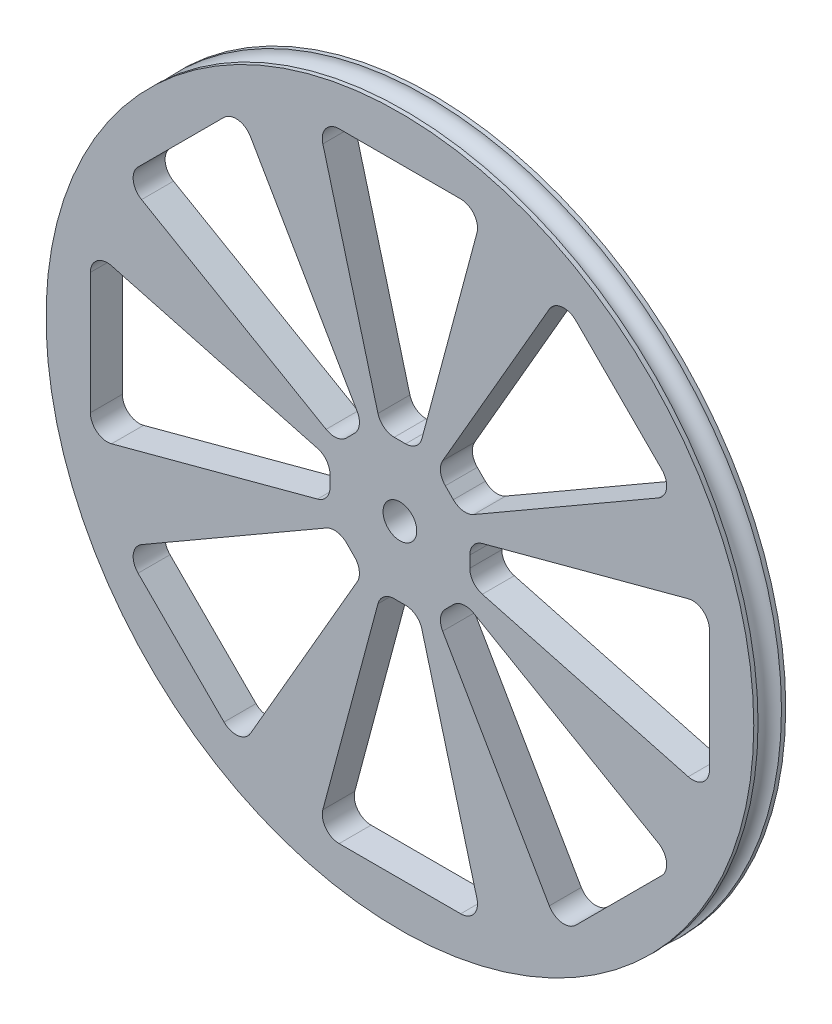
from build123d import *

# Parameters (mm, degrees)
CUT_EXTRUDE1_DEPTH = 7.62


with BuildPart() as part:
    # Sketch1 → Revolve1 (revolve)
    with BuildSketch(Plane(origin=(0, 0, 0), x_dir=(0, 0, -1), z_dir=(1, 0, 0))):
        with BuildLine():
            Line((-2.409610907, -44.48919659), (-2.409610907, 6.31080341))
            Line((-2.409610907, 6.31080341), (-1.7653, 6.31080341))
            ThreePointArc((-1.7653, 6.31080341), (0, 4.54550341), (1.7653, 6.31080341))
            Line((1.7653, 6.31080341), (2.409610907, 6.31080341))
            Line((2.409610907, 6.31080341), (2.409610907, -44.48919659))
            Line((2.409610907, -44.48919659), (-2.409610907, -44.48919659))
        make_face()
    revolve(axis=Axis((0, -47.02919659, 19.251181834), (0, 0, -1)))

    # Sketch2 → Cut-Extrude1 (cut)
    with BuildSketch(Plane(origin=(0, 0, -2.409610907), x_dir=(-1, 0, 0), z_dir=(0, 0, -1))):
        with BuildLine():
            Line((-9.161557863, -0.373493478), (9.161557863, -0.373493478))
            ThreePointArc((9.161557863, -0.373493478), (11.176404431, -1.366886448), (11.615239648, -3.570034182))
            Line((11.615239648, -3.570034182), (3.310434261, -34.607484824))
            ThreePointArc((3.310434261, -34.607484824), (2.403359506, -35.965790688), (0.856752476, -36.490944119))
            Line((0.856752476, -36.490944119), (-0.856752476, -36.490944119))
            ThreePointArc((-0.856752476, -36.490944119), (-2.403359506, -35.965790688), (-3.310434261, -34.607484824))
            Line((-3.310434261, -34.607484824), (-11.615239648, -3.570034182))
            ThreePointArc((-11.615239648, -3.570034182), (-11.176404431, -1.366886448), (-9.161557863, -0.373493478))
        make_face()
        with BuildLine():
            Line((38.943483164, -24.512142867), (11.124307138, -40.586550481))
            ThreePointArc((11.124307138, -40.586550481), (9.52244114, -40.905619058), (8.057485269, -40.183342291))
            Line((8.057485269, -40.183342291), (6.845854298, -38.971711321))
            ThreePointArc((6.845854298, -38.971711321), (6.123577532, -37.506755449), (6.442646109, -35.904889451))
            Line((6.442646109, -35.904889451), (22.517053723, -8.085713426))
            ThreePointArc((22.517053723, -8.085713426), (24.385217783, -6.838156081), (26.512364361, -7.560432847))
            Line((26.512364361, -7.560432847), (39.468763743, -20.516832229))
            ThreePointArc((39.468763743, -20.516832229), (40.191040509, -22.643978806), (38.943483164, -24.512142867))
        make_face()
        with BuildLine():
            Line((43.459162408, -58.644436238), (12.421711766, -50.339630851))
            ThreePointArc((12.421711766, -50.339630851), (11.063405902, -49.432556096), (10.53825247, -47.885949066))
            Line((10.53825247, -47.885949066), (10.53825247, -46.172444114))
            ThreePointArc((10.53825247, -46.172444114), (11.063405902, -44.625837084), (12.421711766, -43.718762329))
            Line((12.421711766, -43.718762329), (43.459162408, -35.413956942))
            ThreePointArc((43.459162408, -35.413956942), (45.662310142, -35.852792158), (46.655703112, -37.867638727))
            Line((46.655703112, -37.867638727), (46.655703112, -56.190754453))
            ThreePointArc((46.655703112, -56.190754453), (45.662310142, -58.205601021), (43.459162408, -58.644436238))
        make_face()
        with BuildLine():
            Line((22.517053723, -85.972679753), (6.442646109, -58.153503728))
            ThreePointArc((6.442646109, -58.153503728), (6.123577532, -56.55163773), (6.845854298, -55.086681859))
            Line((6.845854298, -55.086681859), (8.057485269, -53.875050888))
            ThreePointArc((8.057485269, -53.875050888), (9.52244114, -53.152774122), (11.124307138, -53.471842699))
            Line((11.124307138, -53.471842699), (38.943483164, -69.546250313))
            ThreePointArc((38.943483164, -69.546250313), (40.191040509, -71.414414373), (39.468763743, -73.54156095))
            Line((39.468763743, -73.54156095), (26.512364361, -86.497960333))
            ThreePointArc((26.512364361, -86.497960333), (24.385217783, -87.220237099), (22.517053723, -85.972679753))
        make_face()
        with BuildLine():
            Line((-11.615239648, -90.488358998), (-3.310434261, -59.450908356))
            ThreePointArc((-3.310434261, -59.450908356), (-2.403359506, -58.092602492), (-0.856752476, -57.56744906))
            Line((-0.856752476, -57.56744906), (0.856752476, -57.56744906))
            ThreePointArc((0.856752476, -57.56744906), (2.403359506, -58.092602492), (3.310434261, -59.450908356))
            Line((3.310434261, -59.450908356), (11.615239648, -90.488358998))
            ThreePointArc((11.615239648, -90.488358998), (11.176404431, -92.691506732), (9.161557863, -93.684899702))
            Line((9.161557863, -93.684899702), (-9.161557863, -93.684899702))
            ThreePointArc((-9.161557863, -93.684899702), (-11.176404431, -92.691506732), (-11.615239648, -90.488358998))
        make_face()
        with BuildLine():
            Line((-38.943483164, -69.546250313), (-11.124307138, -53.471842699))
            ThreePointArc((-11.124307138, -53.471842699), (-9.52244114, -53.152774122), (-8.057485269, -53.875050888))
            Line((-8.057485269, -53.875050888), (-6.845854298, -55.086681859))
            ThreePointArc((-6.845854298, -55.086681859), (-6.123577532, -56.55163773), (-6.442646109, -58.153503728))
            Line((-6.442646109, -58.153503728), (-22.517053723, -85.972679753))
            ThreePointArc((-22.517053723, -85.972679753), (-24.385217783, -87.220237099), (-26.512364361, -86.497960333))
            Line((-26.512364361, -86.497960333), (-39.468763743, -73.54156095))
            ThreePointArc((-39.468763743, -73.54156095), (-40.191040509, -71.414414373), (-38.943483164, -69.546250313))
        make_face()
        with BuildLine():
            Line((-43.459162408, -35.413956942), (-12.421711766, -43.718762329))
            ThreePointArc((-12.421711766, -43.718762329), (-11.063405902, -44.625837084), (-10.53825247, -46.172444114))
            Line((-10.53825247, -46.172444114), (-10.53825247, -47.885949066))
            ThreePointArc((-10.53825247, -47.885949066), (-11.063405902, -49.432556096), (-12.421711766, -50.339630851))
            Line((-12.421711766, -50.339630851), (-43.459162408, -58.644436238))
            ThreePointArc((-43.459162408, -58.644436238), (-45.662310142, -58.205601021), (-46.655703112, -56.190754453))
            Line((-46.655703112, -56.190754453), (-46.655703112, -37.867638727))
            ThreePointArc((-46.655703112, -37.867638727), (-45.662310142, -35.852792158), (-43.459162408, -35.413956942))
        make_face()
        with BuildLine():
            Line((-22.517053723, -8.085713426), (-6.442646109, -35.904889451))
            ThreePointArc((-6.442646109, -35.904889451), (-6.123577532, -37.506755449), (-6.845854298, -38.971711321))
            Line((-6.845854298, -38.971711321), (-8.057485269, -40.183342291))
            ThreePointArc((-8.057485269, -40.183342291), (-9.52244114, -40.905619058), (-11.124307138, -40.586550481))
            Line((-11.124307138, -40.586550481), (-38.943483164, -24.512142867))
            ThreePointArc((-38.943483164, -24.512142867), (-40.191040509, -22.643978806), (-39.468763743, -20.516832229))
            Line((-39.468763743, -20.516832229), (-26.512364361, -7.560432847))
            ThreePointArc((-26.512364361, -7.560432847), (-24.385217783, -6.838156081), (-22.517053723, -8.085713426))
        make_face()
    extrude(amount=-CUT_EXTRUDE1_DEPTH, mode=Mode.SUBTRACT)


solid = part.part
